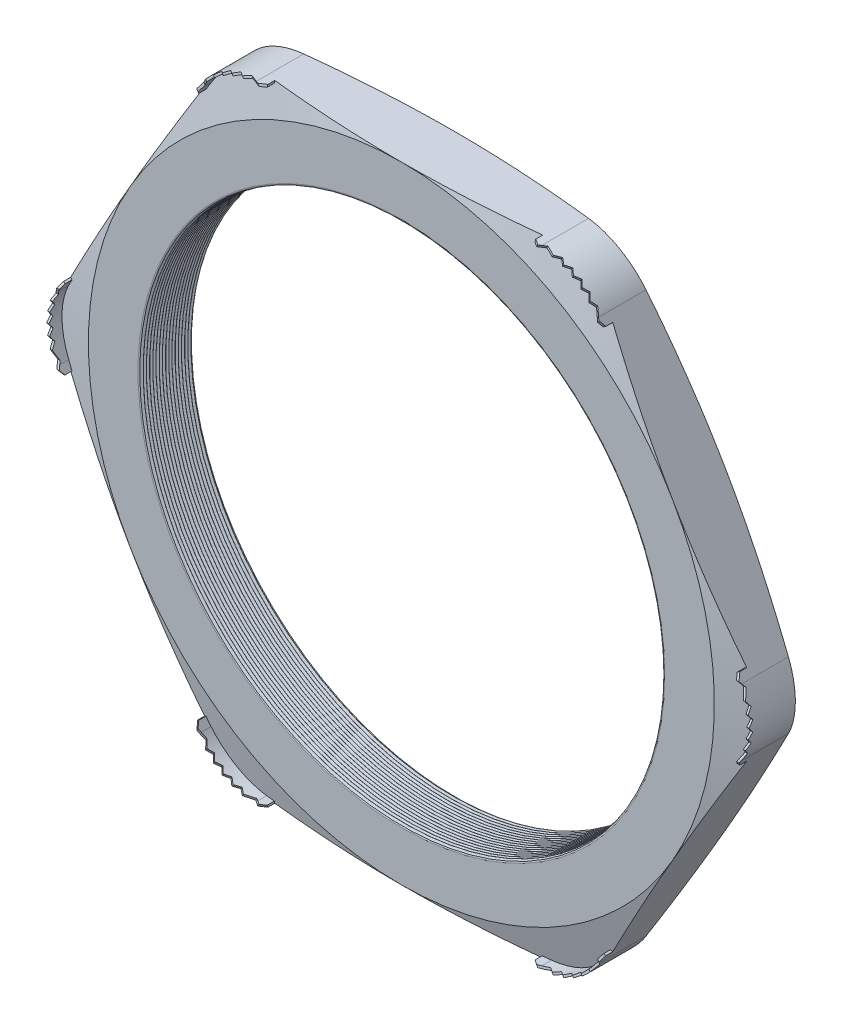
from build123d import *

# Parameters (mm, degrees)
SKETCH1_R          = 25.019
EXTRUDE1_DEPTH     = 5.08
FILLET1_R          = 6.35
FILLET3_R          = 0.2032
LPATTERN1_COUNT    = 17
LPATTERN1_PITCH    = 0.3048
SKETCH4_OUTSIDE_W  = 132.68
SKETCH4_OUTSIDE_H  = 125.372
SKETCH4_OUTSIDE_R  = 29.972
CUT_EXTRUDE1_DEPTH = 6.08
CUT_EXTRUDE1_DRAFT = -75
SKETCH5_OUTSIDE_W  = 132.68
SKETCH5_OUTSIDE_H  = 125.372
SKETCH5_OUTSIDE_R  = 29.972
CUT_EXTRUDE2_DEPTH = 6.0800001
CUT_EXTRUDE2_DRAFT = -75
EXTRUDE2_START     = -0.979177
EXTRUDE2_DEPTH     = 1.893577
CUT_EXTRUDE4_DEPTH = 11.576460528
CIRPATTERN1_COUNT  = 6
CIRPATTERN2_COUNT  = 6


with BuildPart() as part:
    # Sketch1 → Extrude1 (new body)
    with BuildSketch(Plane.XY):
        Polygon((-34.608684536, 0), (-17.304342268, -29.972), (17.304342268, -29.972), (34.608684536, 0), (17.304342268, 29.972), (-17.304342268, 29.972), align=None)
        Circle(SKETCH1_R, mode=Mode.SUBTRACT)
    extrude(amount=EXTRUDE1_DEPTH)

    # Fillet1
    fillet1_edges = [part.edges().sort_by_distance(p)[0] for p in [
        (34.608684536, 0, 2.54),
        (17.304342268, -29.972, 2.54),
        (-17.304342268, -29.972, 2.54),
        (-34.608684536, 0, 2.54),
        (-17.304342268, 29.972, 2.54),
        (17.304342268, 29.972, 2.54),
    ]]
    fillet(fillet1_edges, radius=FILLET1_R)

    # Fillet3
    fillet3_edges = [part.edges().sort_by_distance(p)[0] for p in [
        (-25.019, 0, 0),
        (-25.019, 0, 5.08),
    ]]
    fillet(fillet3_edges, radius=FILLET3_R)

    # Sketch3 → Cut-Revolve1 (revolve, cut)
    with BuildSketch(Plane(origin=(0, 0, 0), x_dir=(1, 0, 0), z_dir=(0, 1, 0)), mode=Mode.PRIVATE) as cut_revolve1_sk:
        Polygon((-25.019, -5.08), (-25.019, -4.786706063), (-25.273, -4.933353032), align=None)
    cut_revolve1 = revolve(cut_revolve1_sk.sketch.rotate(Axis((0, 0, 5.08), (0, 0, -1)), 180), axis=Axis((0, 0, 5.08), (0, 0, -1)), mode=Mode.SUBTRACT)  # turned: the seam where the file's is

    # LPattern1: Cut-Revolve1 ×17
    with Locations(*[(0, 0, -i * LPATTERN1_PITCH) for i in range(1, LPATTERN1_COUNT)]):
        add(cut_revolve1, mode=Mode.SUBTRACT)


with BuildPart() as cut_extrude1_tool:
    # Sketch4 outside → Cut-Extrude1 (with draft: the straight prism first)
    with BuildSketch(Plane(origin=(0, 0, 0), x_dir=(-1, 0, 0), z_dir=(0, 0, -1))):
        Rectangle(SKETCH4_OUTSIDE_W, SKETCH4_OUTSIDE_H)
        Circle(SKETCH4_OUTSIDE_R, mode=Mode.SUBTRACT)
    extrude(amount=-CUT_EXTRUDE1_DEPTH)
    # Cut-Extrude1: the draft: its side faces are tilted about the plane it starts from
    cut_extrude1_sides = [cut_extrude1_tool.faces().sort_by_distance(p)[0] for p in [
        (0, -62.686, 3.04),
        (-66.34, 0, 3.04),
        (0, 62.686, 3.04),
        (66.34, 0, 3.04),
        (29.972, 0, 3.04),
    ]]
    draft(cut_extrude1_sides, Plane(origin=(0, 0, 0), x_dir=(-1, 0, 0), z_dir=(0, 0, -1)), CUT_EXTRUDE1_DRAFT)


with BuildPart() as part_1:
    add(part.part)

    # Cut-Extrude1: cut by cut_extrude1_tool
    add(cut_extrude1_tool.part, mode=Mode.SUBTRACT)


with BuildPart() as cut_extrude2_tool:
    # Sketch5 outside → Cut-Extrude2 (with draft: the straight prism first)
    with BuildSketch(Plane.XY.offset(5.08)):
        Rectangle(SKETCH5_OUTSIDE_W, SKETCH5_OUTSIDE_H)
        Circle(SKETCH5_OUTSIDE_R, mode=Mode.SUBTRACT)
    extrude(amount=-CUT_EXTRUDE2_DEPTH)
    # Cut-Extrude2: the draft: its side faces are tilted about the plane it starts from
    cut_extrude2_sides = [cut_extrude2_tool.faces().sort_by_distance(p)[0] for p in [
        (0, -62.686, 2.03999995),
        (66.34, 0, 2.03999995),
        (0, 62.686, 2.03999995),
        (-66.34, 0, 2.03999995),
        (-29.972, 0, 2.03999995),
    ]]
    draft(cut_extrude2_sides, Plane.XY.offset(5.08), CUT_EXTRUDE2_DRAFT)


with BuildPart() as part_2:
    add(part_1.part)

    # Cut-Extrude2: cut by cut_extrude2_tool
    add(cut_extrude2_tool.part, mode=Mode.SUBTRACT)

    # Sketch2 → Extrude2 (add)
    with BuildSketch(Plane.XY.offset(5.08).offset(EXTRUDE2_START)):
        with BuildLine():
            Line((-13.638168059, 29.972), (-12.825368059, 29.972))
            Line((-12.825368059, 29.972), (-12.825368059, 29.7688))
            Line((-12.825368059, 29.7688), (-13.638168059, 29.7688))
            ThreePointArc((-13.638168059, 29.7688), (-16.711568059, 28.945284952), (-18.961453011, 26.6954))
            Line((-18.961453011, 26.6954), (-19.367853011, 25.991494552))
            Line((-19.367853011, 25.991494552), (-19.543829373, 26.093094552))
            Line((-19.543829373, 26.093094552), (-19.137429373, 26.797))
            ThreePointArc((-19.137429373, 26.797), (-16.813168059, 29.121261314), (-13.638168059, 29.972))
        make_face()
    extrude2 = extrude(amount=EXTRUDE2_DEPTH)

    # Sketch7 → Cut-Extrude4 (cut, through all)
    with BuildSketch(Plane(origin=(-16.096610535, 27.880147276, 0), x_dir=(0.866025404, 0.5, 0), z_dir=(0.5, -0.866025404, 0))):
        Polygon((-3.878905448, 5.03428), (-3.370905448, 5.418328), (-2.862905448, 5.03428), (-2.032, 5.418328), (-1.524, 5.03428), (-1.016, 5.418328), (-0.508, 5.03428), (0, 5.418328), (0.508, 5.03428), (1.016, 5.418328), (1.524, 5.03428), (2.032, 5.418328), (2.54, 5.03428), (3.370905448, 5.418328), (3.878905448, 5.03428), (3.878905448, 5.9944), (-3.878905448, 5.9944), align=None)
    cut_extrude4 = extrude(amount=-CUT_EXTRUDE4_DEPTH, mode=Mode.SUBTRACT)

    # CirPattern1: Extrude2 ×6 about axis
    cirpattern1_axis = Axis((0, 0, 0), (0, 0, 1))
    for i in range(1, CIRPATTERN1_COUNT):
        add(extrude2.rotate(cirpattern1_axis, i * 360 / CIRPATTERN1_COUNT))

    # CirPattern2: Cut-Extrude4 ×6 about axis
    cirpattern2_axis = Axis((0, 0, 0), (0, 0, 1))
    for i in range(1, CIRPATTERN2_COUNT):
        add(cut_extrude4.rotate(cirpattern2_axis, i * 360 / CIRPATTERN2_COUNT), mode=Mode.SUBTRACT)


solid = part_2.part
